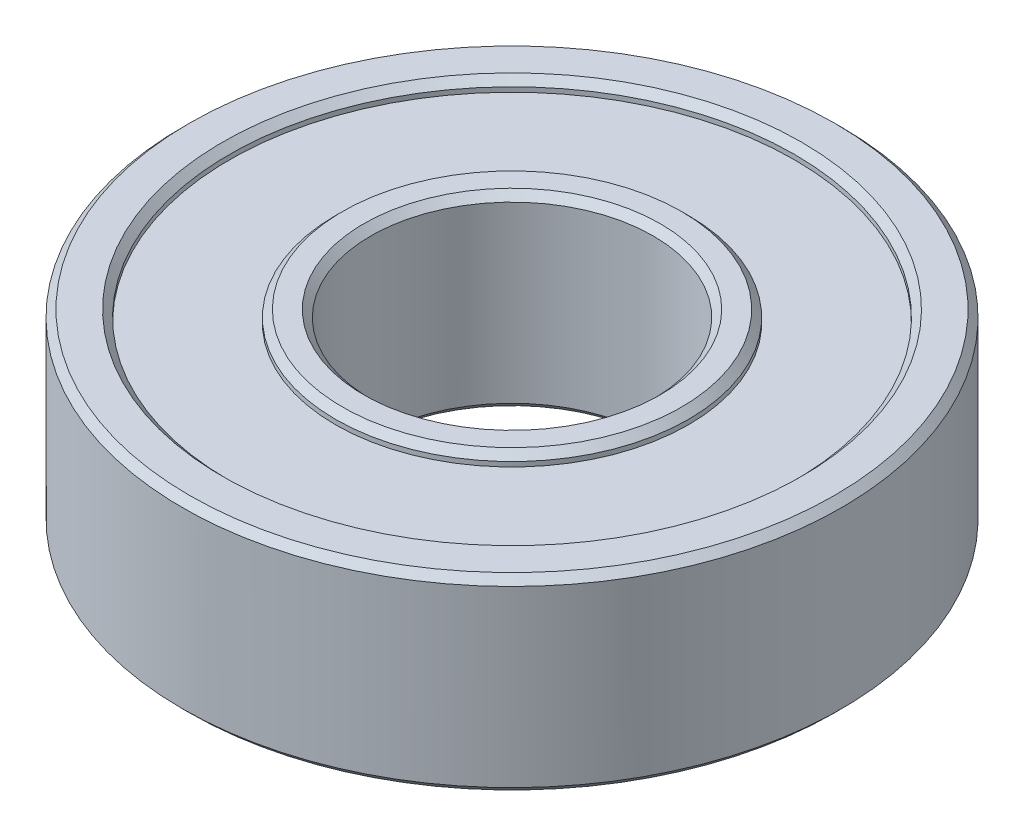
from build123d import *

# Parameters (mm, degrees)
CHAMFER1_SIZE = 0.3


with BuildPart() as part:
    # Sketch1 → Revolve1 (revolve)
    with BuildSketch(Plane.XY):
        Polygon((-6, 0), (-6, 8), (-7.5, 8), (-7.5, 7.5), (-12, 7.5), (-12, 8), (-14, 8), (-14, 0), (-12, 0), (-12, 0.5), (-7.5, 0.5), (-7.5, 0), align=None)
    revolve(axis=Axis((0, 0, 0), (0, 1, 0)))

    # Chamfer1
    chamfer1_edges = [part.edges().sort_by_distance(p)[0] for p in [
        (14, 0, 0),
        (14, 8, 0),
        (12, 8, 0),
        (7.5, 8, 0),
        (6, 8, 0),
        (6, 0, 0),
        (7.5, 0, 0),
        (12, 0, 0),
    ]]
    chamfer(chamfer1_edges, length=CHAMFER1_SIZE)


solid = part.part
